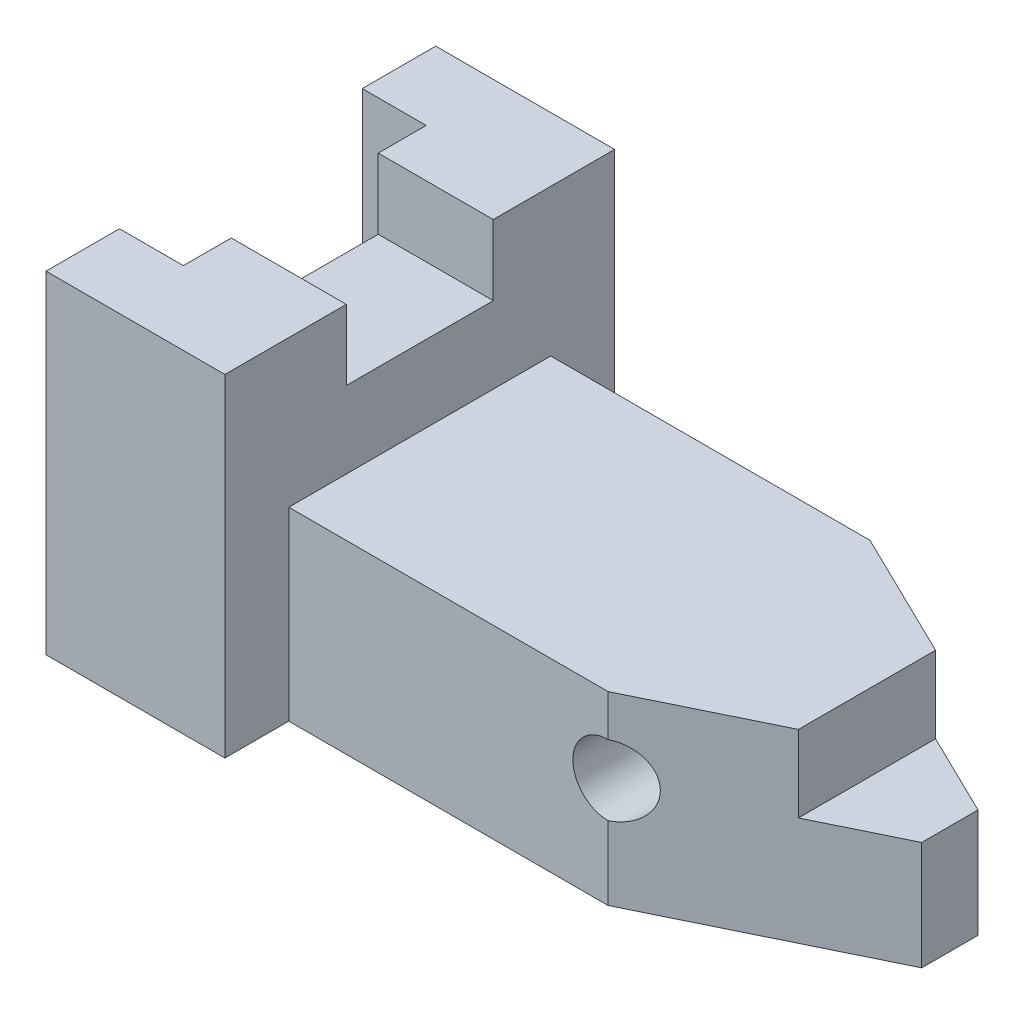
from build123d import *

# Parameters (mm, degrees)
BOSS_EXTRUDE1_DEPTH = 17
BOSS_EXTRUDE2_DEPTH = 29
BOSS_EXTRUDE3_DEPTH = 41
BOSS_EXTRUDE4_DEPTH = 52
SKETCH2_R           = 5.5
CUT_EXTRUDE1_DEPTH  = 133.736838113


with BuildPart() as part:
    # Sketch1 → Boss-Extrude1 (new body)
    with BuildSketch(Plane(origin=(0, 0, 0), x_dir=(1, 0, 0), z_dir=(0, 1, 0))):
        Polygon((10, -19), (0, -19), (0, -30.5), (28, -30.5), (28, -20.5), (77.968771248, -20.5), (110.968771248, -4.404824577), (110.968771248, 4.404824577), (77.968771248, 20.5), (28, 20.5), (28, 30.5), (0, 30.5), (0, 19), (10, 19), align=None)
    extrude(amount=BOSS_EXTRUDE1_DEPTH)

    # Sketch1_3 → Boss-Extrude2 (add)
    with BuildSketch(Plane(origin=(0, 0, 0), x_dir=(1, 0, 0), z_dir=(0, 1, 0))):
        Polygon((10, -19), (0, -19), (0, -30.5), (28, -30.5), (28, -20.5), (77.968771248, -20.5), (98, -10.730116948), (98, 10.730116948), (77.968771248, 20.5), (28, 20.5), (28, 30.5), (0, 30.5), (0, 19), (10, 19), align=None)
    extrude(amount=BOSS_EXTRUDE2_DEPTH)

    # Sketch1_4 → Boss-Extrude3 (add)
    with BuildSketch(Plane(origin=(0, 0, 0), x_dir=(1, 0, 0), z_dir=(0, 1, 0))):
        Polygon((10, -19), (0, -19), (0, -30.5), (28, -30.5), (28, 30.5), (0, 30.5), (0, 19), (10, 19), align=None)
    extrude(amount=BOSS_EXTRUDE3_DEPTH)

    # Sketch1_5 → Boss-Extrude4 (add)
    with BuildSketch(Plane(origin=(0, 0, 0), x_dir=(1, 0, 0), z_dir=(0, 1, 0))):
        Polygon((10, -19), (0, -19), (0, -30.5), (28, -30.5), (28, -11.5), (10, -11.5), align=None)
        Polygon((10, 19), (10, 11.5), (28, 11.5), (28, 30.5), (0, 30.5), (0, 19), align=None)
    extrude(amount=BOSS_EXTRUDE4_DEPTH)

    # Sketch2 → Cut-Extrude1 (cut, through all)
    with BuildSketch(Plane.XY.offset(20.5)):
        with Locations((77.968771248, 17)):
            Circle(SKETCH2_R)
    extrude(amount=-CUT_EXTRUDE1_DEPTH, mode=Mode.SUBTRACT)


solid = part.part
